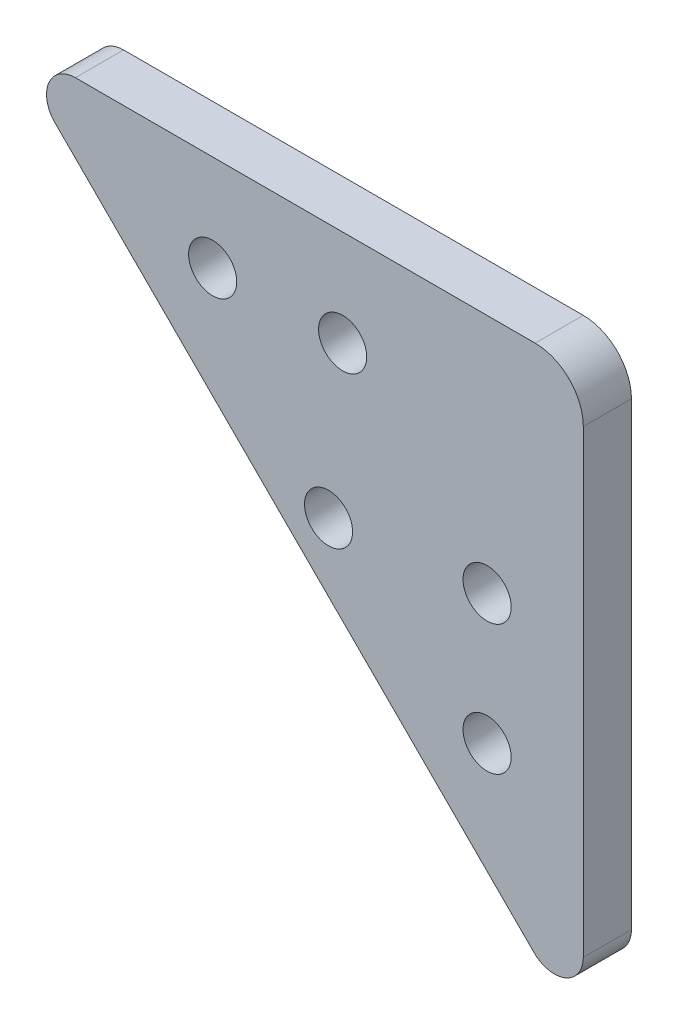
from build123d import *

# Parameters (mm, degrees)
SKETCH1_R           = 2.5
BOSS_EXTRUDE2_DEPTH = 5


with BuildPart() as part:
    # Sketch1 → Boss-Extrude2 (new body)
    with BuildSketch(Plane.XY):
        with BuildLine():
            Line((-22.757359313, 30), (25, 30))
            ThreePointArc((25, 30), (28.535533906, 28.535533906), (30, 25))
            Line((30, 25), (30, -22.757359313))
            ThreePointArc((30, -22.757359313), (28.148050297, -25.52899791), (24.878679656, -24.878679656))
            Line((24.878679656, -24.878679656), (-24.878679656, 24.878679656))
            ThreePointArc((-24.878679656, 24.878679656), (-25.52899791, 28.148050297), (-22.757359313, 30))
        make_face()
        with Locations((5, 20.006442339)):
            Circle(SKETCH1_R, mode=Mode.SUBTRACT)
        with Locations((-8.5, 20.006442339)):
            Circle(SKETCH1_R, mode=Mode.SUBTRACT)
        with Locations((20.006442339, 5)):
            Circle(SKETCH1_R, mode=Mode.SUBTRACT)
        with Locations((20.006442339, -8.5)):
            Circle(SKETCH1_R, mode=Mode.SUBTRACT)
        with Locations((3.535533906, 3.535533906)):
            Circle(SKETCH1_R, mode=Mode.SUBTRACT)
    extrude(amount=BOSS_EXTRUDE2_DEPTH)


solid = part.part
